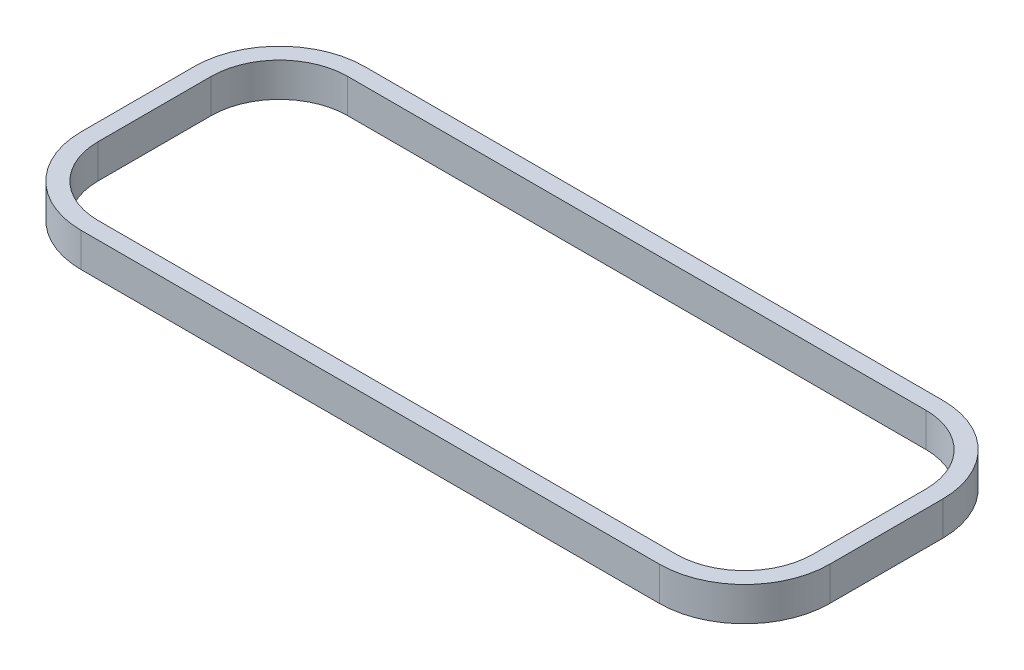
from build123d import *

# Parameters (mm, degrees)
BOSS_EXTRUDE1_DEPTH = 19.05


with BuildPart() as part:
    # Sketch1 → Boss-Extrude1 (new body)
    with BuildSketch(Plane(origin=(0, 0, 0), x_dir=(1, 0, 0), z_dir=(0, 1, 0))):
        with BuildLine():
            Line((-161.416063287, 5.181424099), (-161.416063287, -58.064575901))
            ThreePointArc((-161.416063287, -58.064575901), (-147.429826303, -91.830338916), (-113.664063287, -105.816575901))
            Line((-113.664063287, -105.816575901), (209.931936713, -105.816575901))
            ThreePointArc((209.931936713, -105.816575901), (243.697699728, -91.830338916), (257.683936713, -58.064575901))
            Line((257.683936713, -58.064575901), (257.683936713, 5.181424099))
            ThreePointArc((257.683936713, 5.181424099), (243.697699728, 38.947187114), (209.931936713, 52.933424099))
            Line((209.931936713, 52.933424099), (-113.664063287, 52.933424099))
            ThreePointArc((-113.664063287, 52.933424099), (-147.429826303, 38.947187114), (-161.416063287, 5.181424099))
        make_face()
        with BuildLine():
            Line((-151.891063287, 5.181424099), (-151.891063287, -58.064575901))
            ThreePointArc((-151.891063287, -58.064575901), (-140.694634212, -85.095146825), (-113.664063287, -96.291575901))
            Line((-113.664063287, -96.291575901), (209.931936713, -96.291575901))
            ThreePointArc((209.931936713, -96.291575901), (236.962507637, -85.095146825), (248.158936713, -58.064575901))
            Line((248.158936713, -58.064575901), (248.158936713, 5.181424099))
            ThreePointArc((248.158936713, 5.181424099), (236.962507637, 32.211995024), (209.931936713, 43.408424099))
            Line((209.931936713, 43.408424099), (-113.664063287, 43.408424099))
            ThreePointArc((-113.664063287, 43.408424099), (-140.694634212, 32.211995024), (-151.891063287, 5.181424099))
        make_face(mode=Mode.SUBTRACT)
    extrude(amount=BOSS_EXTRUDE1_DEPTH)


solid = part.part
